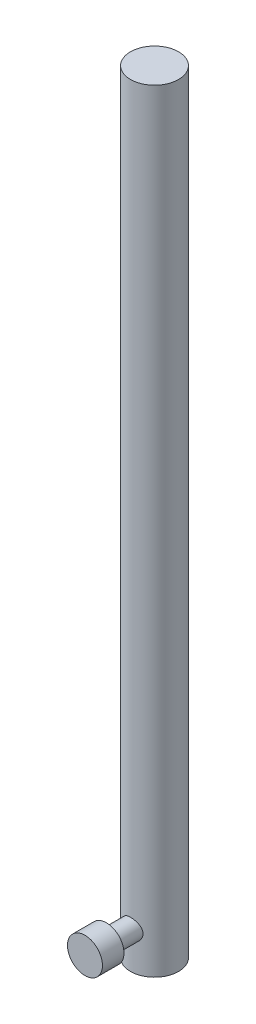
from build123d import *

# Parameters (mm, degrees)
SKETCH1_R           = 3.175
EXTRUDE1_DEPTH      = 102.108
SKETCH2_R           = 1
EXTRUDE2_DEPTH      = 6.35
SKETCH4_R           = 1.35382
BOSS_EXTRUDE2_DEPTH = 6.35
SKETCH5_R           = 2.3114
BOSS_EXTRUDE3_DEPTH = 2.8448


with BuildPart() as part:
    # Sketch1 → Extrude1 (new body)
    with BuildSketch(Plane(origin=(0, 0, 0), x_dir=(1, 0, 0), z_dir=(0, 1, 0))):
        with Locations(Location((0, 0, 0), (0, 0, 270))):  # turned: the seam where the file's is
            Circle(SKETCH1_R)
    extrude(amount=EXTRUDE1_DEPTH)

    # Sketch2 → Extrude2 (cut)
    with BuildSketch(Plane.XZ):
        with Locations(Location((0, 0, 0), (0, 0, 270))):  # turned: the seam where the file's is
            Circle(SKETCH2_R)
    extrude(amount=-EXTRUDE2_DEPTH, mode=Mode.SUBTRACT)

    # Sketch4 → Boss-Extrude2 (add)
    with BuildSketch(Plane.XY):
        with Locations(Location((0, 4.85382, 0), (0, 0, 180))):  # turned: the seam where the file's is
            Circle(SKETCH4_R)
    extrude(amount=BOSS_EXTRUDE2_DEPTH)

    # Sketch5 → Boss-Extrude3 (add)
    with BuildSketch(Plane.XY.offset(6.35)):
        with Locations((0, 4.85382)):
            Circle(SKETCH5_R)
    extrude(amount=BOSS_EXTRUDE3_DEPTH)


solid = part.part
